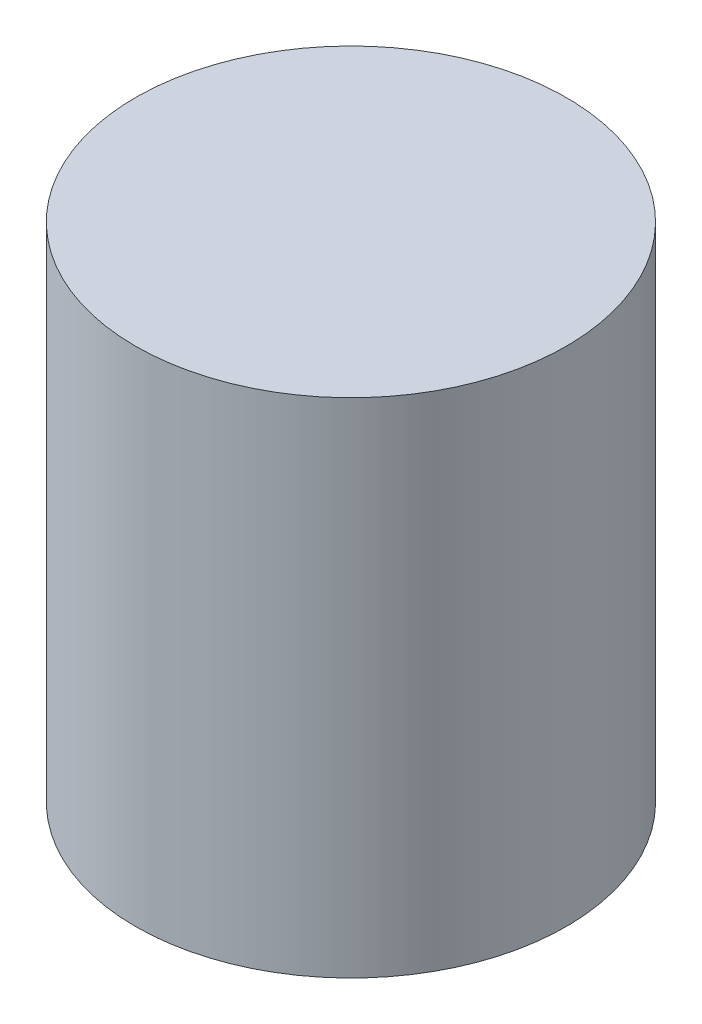
from build123d import *

# Parameters (mm, degrees)
SKETCH_1_R      = 3
EXTRUDE_1_DEPTH = 7


with BuildPart() as part:
    # Эскиз1 → Бобышка-Вытянуть1 (new body)
    with BuildSketch(Plane(origin=(0, 0, 0), x_dir=(1, 0, 0), z_dir=(0, 1, 0))):
        Circle(SKETCH_1_R)
    extrude(amount=EXTRUDE_1_DEPTH)


solid = part.part
